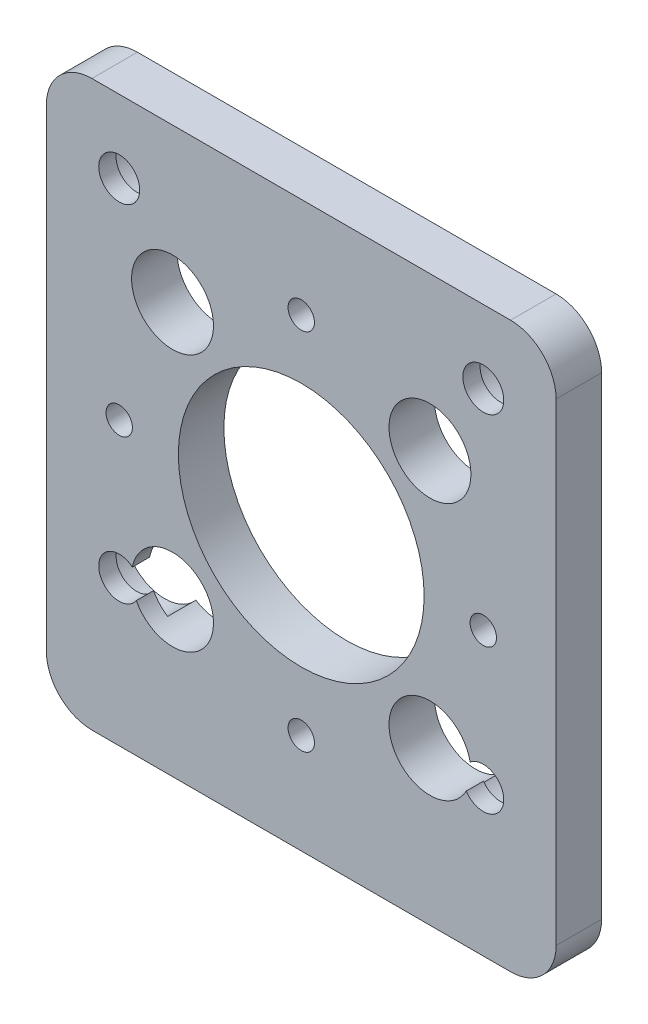
from build123d import *

# Parameters (mm, degrees)
SKETCH1_W                                        = 56
SKETCH1_H                                        = 62
SKETCH1_R                                        = 13.5
BOSS_EXTRUDE1_DEPTH                              = 5
M2_5_CLEARANCE_HOLE1_D                           = 2.9
CBORE_FOR_M4_PAN_HEAD_MACHINE_SCREW1_D           = 4.5
CBORE_FOR_M4_PAN_HEAD_MACHINE_SCREW1_CBORE_D     = 9
CBORE_FOR_M4_PAN_HEAD_MACHINE_SCREW1_CBORE_DEPTH = 3.1
FILLET1_R                                        = 5
SKETCH6_R                                        = 4.5
CUT_EXTRUDE1_DEPTH                               = 6
CUT_EXTRUDE1_DEPTH_BACK                          = 1


with BuildPart() as part:
    # Sketch1 → Boss-Extrude1 (new body)
    with BuildSketch(Plane.XY):
        Rectangle(SKETCH1_W, SKETCH1_H)
        Circle(SKETCH1_R, mode=Mode.SUBTRACT)
    extrude(amount=BOSS_EXTRUDE1_DEPTH)

    # M2.5 Clearance Hole1 (through all)
    with Locations(Plane(origin=(0, 0, 0), x_dir=(-1, 0, 0), z_dir=(0, 0, -1))):
        with Locations((0, 20), (0, -20), (20, 0), (-20, 0)):
            Hole(M2_5_CLEARANCE_HOLE1_D / 2)

    # CBORE for M4 Pan Head Machine Screw1 (through all)
    with Locations(Plane(origin=(0, 0, 0), x_dir=(-1, 0, 0), z_dir=(0, 0, -1))):
        with Locations((-20, 23), (20, 23), (20, -15), (-20, -15)):
            CounterBoreHole(CBORE_FOR_M4_PAN_HEAD_MACHINE_SCREW1_D / 2, CBORE_FOR_M4_PAN_HEAD_MACHINE_SCREW1_CBORE_D / 2, CBORE_FOR_M4_PAN_HEAD_MACHINE_SCREW1_CBORE_DEPTH)

    # Fillet1
    fillet1_edges = [part.edges().sort_by_distance(p)[0] for p in [
        (28, -31, 2.5),
        (-28, -31, 2.5),
        (-28, 31, 2.5),
        (28, 31, 2.5),
    ]]
    fillet(fillet1_edges, radius=FILLET1_R)

    # Sketch6 → Cut-Extrude1 (cut, two sides)
    with BuildSketch(Plane.XY) as cut_extrude1_sk:
        with Locations((-14.142135624, -14.142135624)):
            Circle(SKETCH6_R)
        with Locations((-14.142135624, 14.142135624)):
            Circle(SKETCH6_R)
        with Locations((14.142135624, 14.142135624)):
            Circle(SKETCH6_R)
        with Locations((14.142135624, -14.142135624)):
            Circle(SKETCH6_R)
    extrude(amount=CUT_EXTRUDE1_DEPTH, mode=Mode.SUBTRACT)
    extrude(cut_extrude1_sk.sketch, amount=-CUT_EXTRUDE1_DEPTH_BACK, mode=Mode.SUBTRACT)


solid = part.part
